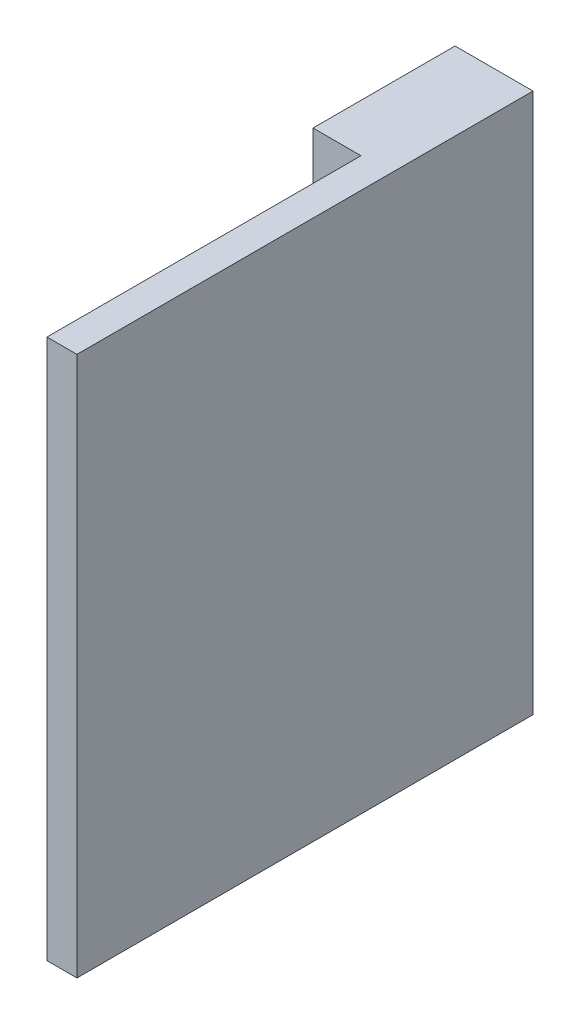
from build123d import *

# Parameters (mm, degrees)
RESSALTO_EXTRUS_O1_DEPTH = 2700


with BuildPart() as part:
    # Esboço1 → Ressalto-extrusão1 (new body)
    with BuildSketch(Plane(origin=(0, 0, 0), x_dir=(1, 0, 0), z_dir=(0, 1, 0))):
        Polygon((0, 0), (150, 0), (150, 2280), (-240, 2280), (-240, 1570), (0, 1570), align=None)
    extrude(amount=RESSALTO_EXTRUS_O1_DEPTH)


solid = part.part
